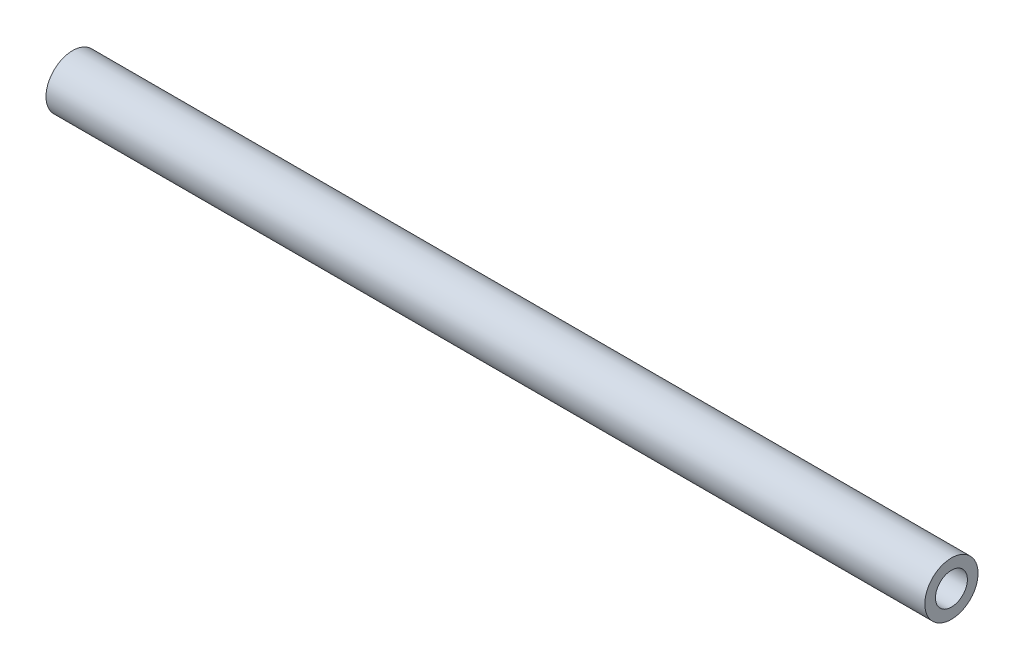
from build123d import *

# Parameters (mm, degrees)
SKETCH1_W = 165
SKETCH1_H = 2


with BuildPart() as part:
    # Sketch1 → Revolve1 (revolve)
    with BuildSketch(Plane(origin=(0, 0, 0), x_dir=(-1, 0, 0), z_dir=(0, 0, -1))):
        with Locations((-82.5, 4)):
            Rectangle(SKETCH1_W, SKETCH1_H)
    revolve(axis=Axis((165, 0, 0), (-1, 0, 0)))


solid = part.part
